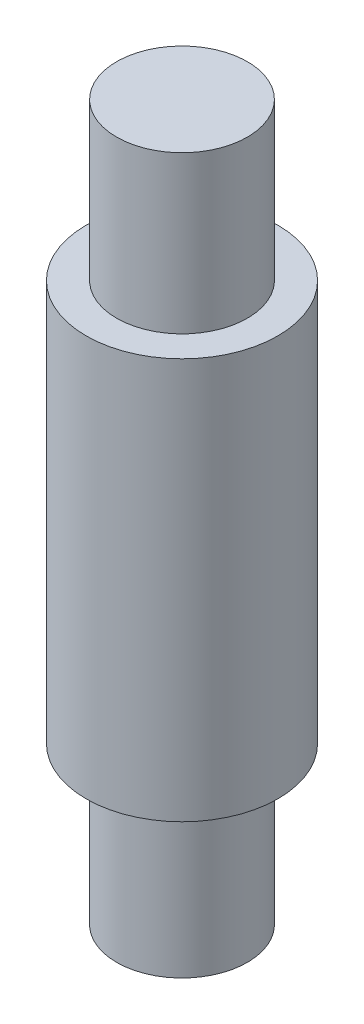
from build123d import *

# Parameters (mm, degrees)
SKETCH1_R           = 11
BOSS_EXTRUDE1_DEPTH = 23
SKETCH1_3_R         = 7.5
BOSS_EXTRUDE2_DEPTH = 41


with BuildPart() as part:
    # Sketch1 → Boss-Extrude1 (new, symmetric)
    with BuildSketch(Plane(origin=(0, 0, 0), x_dir=(1, 0, 0), z_dir=(0, 1, 0))):
        Circle(SKETCH1_R)
    extrude(amount=BOSS_EXTRUDE1_DEPTH, both=True)

    # Sketch1_3 → Boss-Extrude2 (add, symmetric)
    with BuildSketch(Plane(origin=(0, 0, 0), x_dir=(1, 0, 0), z_dir=(0, 1, 0))):
        Circle(SKETCH1_3_R)
    extrude(amount=BOSS_EXTRUDE2_DEPTH, both=True)


solid = part.part
